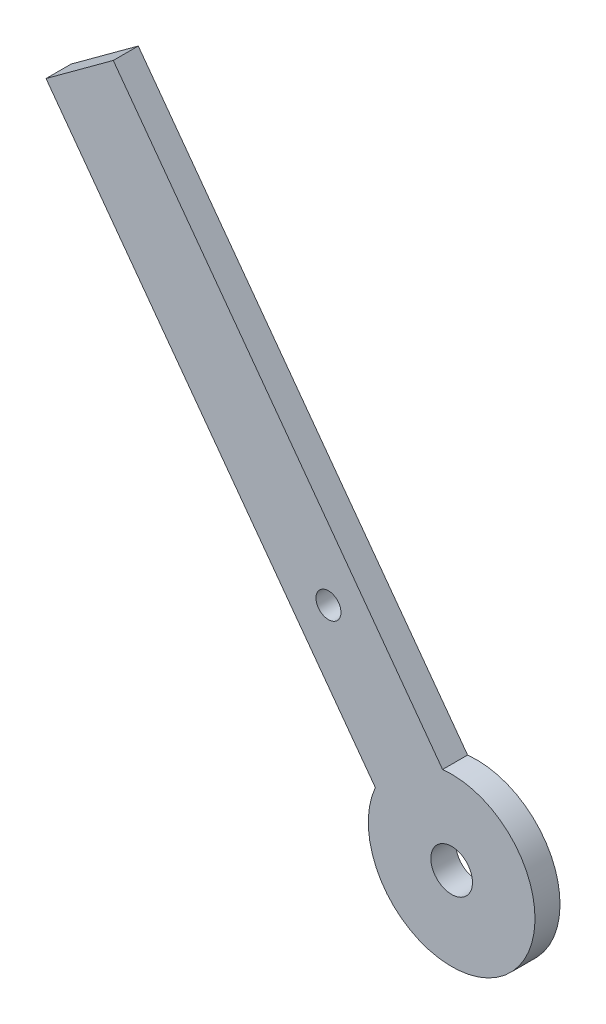
from build123d import *

# Parameters (mm, degrees)
SKETCH1_R           = 2.5
SKETCH1_R_2         = 1.500000002
BOSS_EXTRUDE1_DEPTH = 3


with BuildPart() as part:
    # Sketch1 → Boss-Extrude1 (new body)
    with BuildSketch(Plane.XY):
        with BuildLine():
            Line((8.260955194, 114.775997772), (4.228011812, 111.82043223))
            Line((4.228011812, 111.82043223), (43.737861818, 57.90825))
            ThreePointArc((43.737861818, 57.90825), (58.80112597, 45.812665936), (51.803748583, 63.819381085))
            Line((51.803748583, 63.819381085), (12.293898576, 117.731563314))
            Line((12.293898576, 117.731563314), (8.260955194, 114.775997772))
        make_face()
        with Locations((52.889994885, 53.8785527)):
            Circle(SKETCH1_R, mode=Mode.SUBTRACT)
        with Locations((38.112167173, 74.043269611)):
            Circle(SKETCH1_R_2, mode=Mode.SUBTRACT)
    extrude(amount=BOSS_EXTRUDE1_DEPTH)


solid = part.part
